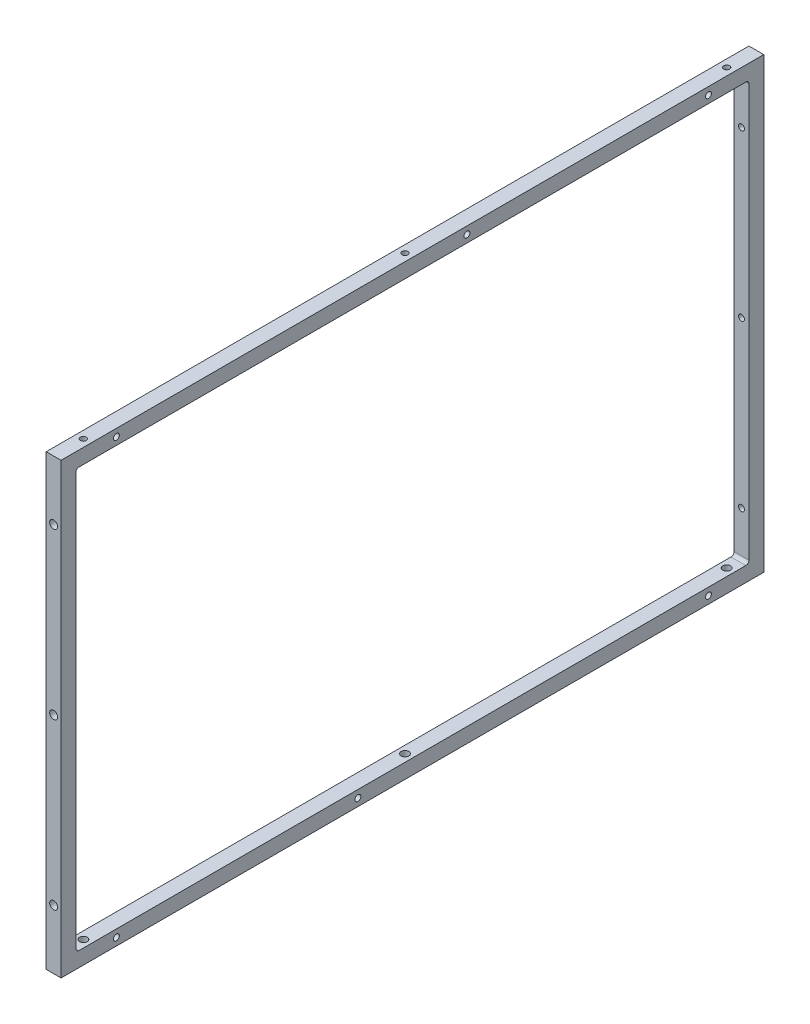
from build123d import *

# Parameters (mm, degrees)
SKETCH1_W                   = 451
SKETCH1_H                   = 287.7714167
SKETCH1_W_2                 = 431.95
SKETCH1_H_2                 = 268.7214167
EXTRUDE_THIN1_DEPTH         = 9.525
FILLET1_R                   = 2
F_10_CLEARANCE_HOLE1_D      = 4.9784
F_10_CLEARANCE_HOLE1_DEPTH  = 9.525
F_10_24_TAPPED_HOLE1_D      = 3.7973
F_10_24_TAPPED_HOLE1_DEPTH  = 14.95
F_10_24_TAPPED_HOLE1_TIP    = 1.140824014
F_10_CLEARANCE_HOLE2_D      = 5.1054
F_10_CLEARANCE_HOLE2_DEPTH  = 20
F_10_CLEARANCE_HOLE2_TIP    = 1.533816902
F_10_24_TAPPED_HOLE2_SIDE_D = 3.7973
F_10_24_TAPPED_HOLE2_D      = 3.7973
F_10_24_TAPPED_HOLE2_DEPTH  = 14.95
F_10_24_TAPPED_HOLE2_TIP    = 1.140824014


with BuildPart() as part:
    # Sketch1 → Extrude-Thin1 (new body)
    with BuildSketch(Plane(origin=(0, 0, 0), x_dir=(0, 0, -1), z_dir=(1, 0, 0))):
        Rectangle(SKETCH1_W, SKETCH1_H)
        Rectangle(SKETCH1_W_2, SKETCH1_H_2, mode=Mode.SUBTRACT)
    extrude(amount=EXTRUDE_THIN1_DEPTH)

    # Fillet1
    fillet1_edges = [part.edges().sort_by_distance(p)[0] for p in [
        (4.7625, 134.36070835, 215.975),
        (4.7625, -134.36070835, 215.975),
        (4.7625, -134.36070835, -215.975),
        (4.7625, 134.36070835, -215.975),
    ]]
    fillet(fillet1_edges, radius=FILLET1_R)

    # #10 Clearance Hole1
    with Locations(Plane(origin=(0, -143.88570835, 0), x_dir=(-1, 0, 0), z_dir=(0, -1, 0))):
        with Locations((-4.7625, 206.45), (-4.7625, 0), (-4.7625, -206.45)):
            Hole(F_10_CLEARANCE_HOLE1_D / 2, depth=F_10_CLEARANCE_HOLE1_DEPTH)

    # #10-24 Tapped Hole1
    with Locations(Plane(origin=(0, 0, -225.5), x_dir=(-1, 0, 0), z_dir=(0, 0, -1))):
        with Locations((-4.7625, 105.78570835), (-4.7625, 0), (-4.7625, -105.78570835)):
            Hole(F_10_24_TAPPED_HOLE1_D / 2, depth=F_10_24_TAPPED_HOLE1_DEPTH)
            with Locations((0, 0, -(F_10_24_TAPPED_HOLE1_DEPTH + F_10_24_TAPPED_HOLE1_TIP / 2))):  # 118° drill point
                Cone(0, F_10_24_TAPPED_HOLE1_D / 2, F_10_24_TAPPED_HOLE1_TIP, mode=Mode.SUBTRACT)

    # #10 Clearance Hole2
    with Locations(Plane.XY.offset(225.5)):
        with Locations((4.7625, 105.78570835), (4.7625, 0), (4.7625, -105.78570835)):
            Hole(F_10_CLEARANCE_HOLE2_D / 2, depth=F_10_CLEARANCE_HOLE2_DEPTH)
            with Locations((0, 0, -(F_10_CLEARANCE_HOLE2_DEPTH + F_10_CLEARANCE_HOLE2_TIP / 2))):  # 118° drill point
                Cone(0, F_10_CLEARANCE_HOLE2_D / 2, F_10_CLEARANCE_HOLE2_TIP, mode=Mode.SUBTRACT)

    # #10-24 Tapped Hole2 side (through all)
    with Locations(Plane.ZY):
        with Locations((-190, 139.12320835), (-35, 139.12320835), (-190, -139.12320835), (35, -139.12320835), (190, -139.12320835), (190, 139.12320835)):
            Hole(F_10_24_TAPPED_HOLE2_SIDE_D / 2)

    # #10-24 Tapped Hole2
    with Locations(Plane(origin=(0, 143.88570835, 0), x_dir=(1, 0, 0), z_dir=(0, 1, 0))):
        with Locations((4.7625, 206.45), (4.7625, 0), (4.7625, -206.45)):
            Hole(F_10_24_TAPPED_HOLE2_D / 2, depth=F_10_24_TAPPED_HOLE2_DEPTH)
            with Locations((0, 0, -(F_10_24_TAPPED_HOLE2_DEPTH + F_10_24_TAPPED_HOLE2_TIP / 2))):  # 118° drill point
                Cone(0, F_10_24_TAPPED_HOLE2_D / 2, F_10_24_TAPPED_HOLE2_TIP, mode=Mode.SUBTRACT)


solid = part.part
